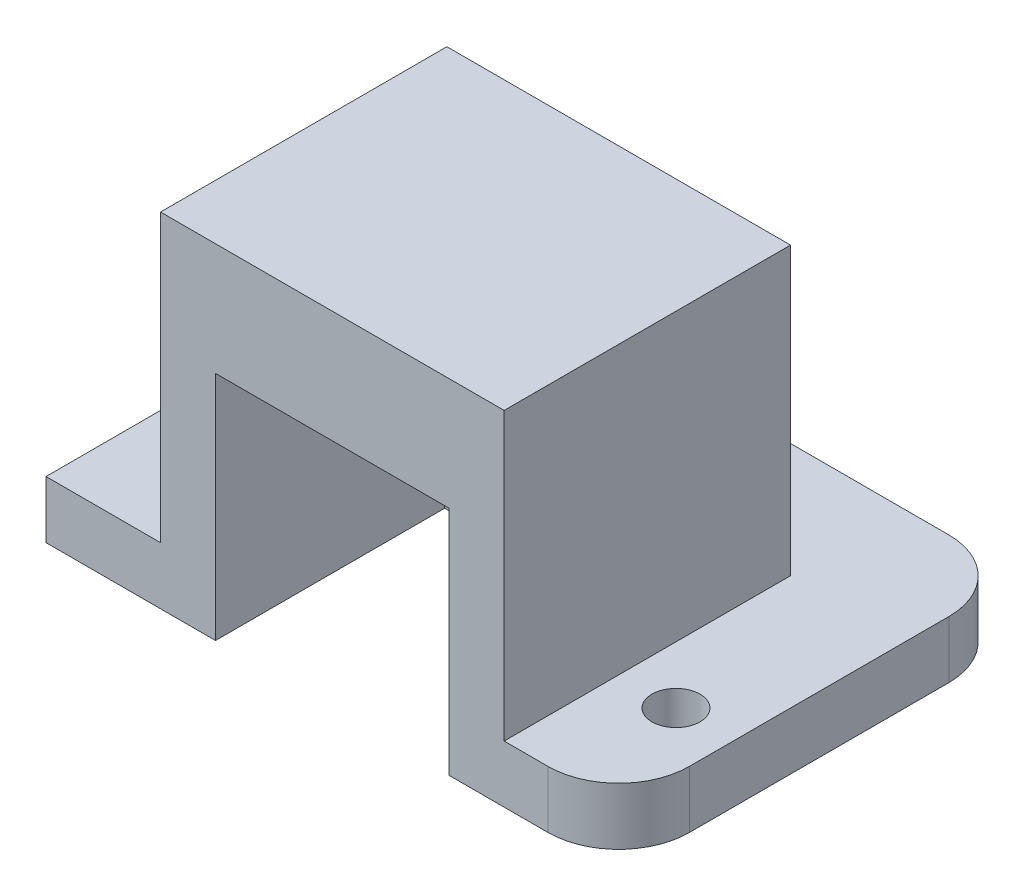
from build123d import *

# Parameters (mm, degrees)
SKETCH_1_W          = 30
SKETCH_1_H          = 30
EXTRUDE_1_DEPTH     = 5
SKETCH_2_W          = 30
SKETCH_2_H          = 5
EXTRUDE_2_DEPTH     = 10
SKETCH_3_R          = 2.1
CUT_EXTRUDE_1_DEPTH = 5
EXTRUDE_3_DEPTH     = 20
SKETCH_5_W          = 35
SKETCH_5_H          = 5
EXTRUDE_4_DEPTH     = 10
SKETCH_6_W          = 35
SKETCH_6_H          = 5
EXTRUDE_5_DEPTH     = 10
SKETCH_7_R          = 2.1
CUT_EXTRUDE_2_DEPTH = 10
FILLET_1_R          = 6.17
FILLET_2_R          = 6.17


with BuildPart() as part:
    # 스케치1 → 보스-돌출1 (new body)
    with BuildSketch(Plane.XY):
        Rectangle(SKETCH_1_W, SKETCH_1_H)
    extrude(amount=EXTRUDE_1_DEPTH)

    # 스케치2 → 보스-돌출2 (add)
    with BuildSketch(Plane(origin=(0, 0, 0), x_dir=(-1, 0, 0), z_dir=(0, 0, -1))):
        with Locations((0, -12.5)):
            Rectangle(SKETCH_2_W, SKETCH_2_H)
    extrude(amount=EXTRUDE_2_DEPTH)

    # 스케치3 → 컷-돌출1 (cut)
    with BuildSketch(Plane(origin=(0, -10, 0), x_dir=(1, 0, 0), z_dir=(0, 1, 0))):
        with Locations((0, 5)):
            Circle(SKETCH_3_R)
    extrude(amount=-CUT_EXTRUDE_1_DEPTH, mode=Mode.SUBTRACT)

    # 스케치4 → 보스-돌출3 (add)
    with BuildSketch(Plane.XY.offset(5)):
        Polygon((10.2, -15), (15, -15), (15, 15), (-15, 15), (-15, -15), (-10.2, -15), (-10.2, 5.2), (10.2, 5.2), align=None)
    extrude(amount=EXTRUDE_3_DEPTH)

    # 스케치5 → 보스-돌출4 (add)
    with BuildSketch(Plane.ZY.offset(15)):
        with Locations((7.5, -12.5)):
            Rectangle(SKETCH_5_W, SKETCH_5_H)
    extrude(amount=EXTRUDE_4_DEPTH)

    # 스케치6 → 보스-돌출5 (add)
    with BuildSketch(Plane(origin=(15, 0, 0), x_dir=(0, 0, -1), z_dir=(1, 0, 0))):
        with Locations((-7.5, -12.5)):
            Rectangle(SKETCH_6_W, SKETCH_6_H)
    extrude(amount=EXTRUDE_5_DEPTH)

    # 스케치7 → 컷-돌출2 (cut)
    with BuildSketch(Plane(origin=(0, -10, 0), x_dir=(1, 0, 0), z_dir=(0, 1, 0))):
        with Locations((-20, -15)):
            Circle(SKETCH_7_R)
        with Locations((20, -15)):
            Circle(SKETCH_7_R)
    extrude(amount=-CUT_EXTRUDE_2_DEPTH, mode=Mode.SUBTRACT)

    # 필렛1
    fillet_1_edges = [part.edges().sort_by_distance(p)[0] for p in [
        (25, -12.5, 25),
    ]]
    fillet(fillet_1_edges, radius=FILLET_1_R)

    # 필렛2
    fillet_2_edges = [part.edges().sort_by_distance(p)[0] for p in [
        (25, -12.5, -10),
    ]]
    fillet(fillet_2_edges, radius=FILLET_2_R)


solid = part.part
